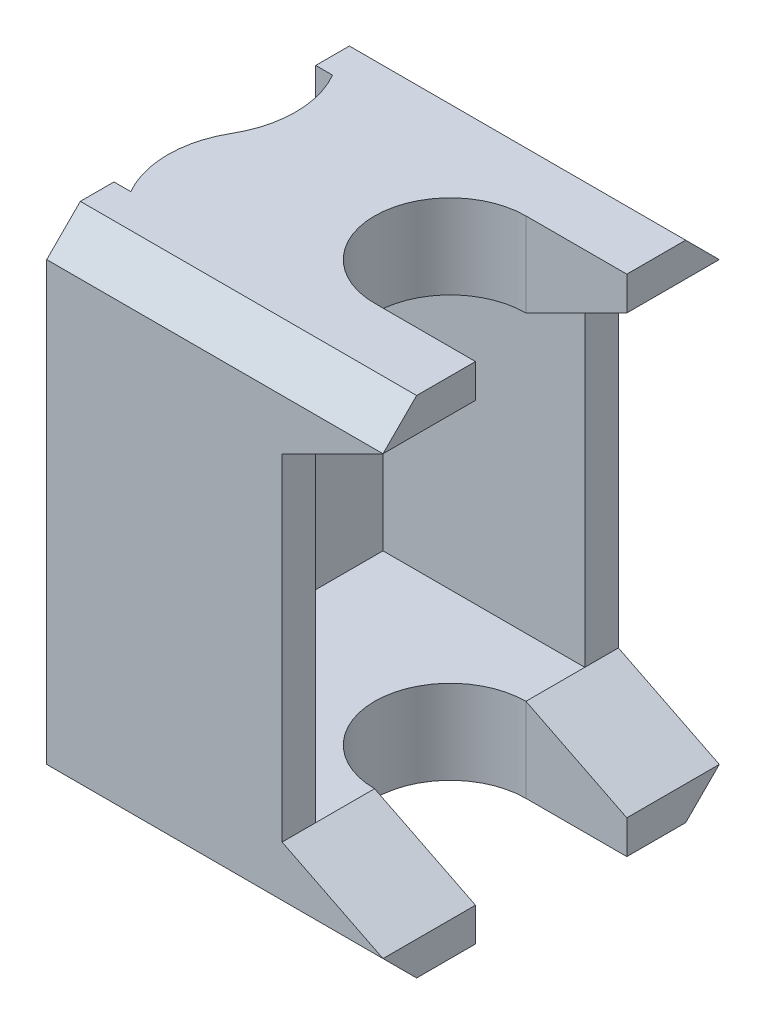
from build123d import *

# Parameters (mm, degrees)
BOSS_EXTRUDE1_DEPTH = 50
CUT_EXTRUDE1_DEPTH  = 151
SKETCH3_W           = 80
SKETCH3_H           = 100
CUT_EXTRUDE3_DEPTH  = 60
CUT_EXTRUDE4_DEPTH  = 101


with BuildPart() as part:
    # Sketch1 → Boss-Extrude1 (new body, symmetric)
    with BuildSketch(Plane.XY):
        Polygon((0, 0), (0, 10), (-30, 25), (-30, 125), (0, 140), (0, 150), (-100, 150), (-100, 0), align=None)
    extrude(amount=BOSS_EXTRUDE1_DEPTH, both=True)

    # Sketch2 → Cut-Extrude1 (cut, through all)
    with BuildSketch(Plane(origin=(0, 150, 0), x_dir=(1, 0, 0), z_dir=(0, 1, 0))):
        with BuildLine():
            Line((0, 22.5), (-30, 22.5))
            ThreePointArc((-30, 22.5), (-52.5, 0), (-30, -22.5))
            Line((-30, -22.5), (0, -22.5))
            Line((0, -22.5), (0, 22.5))
        make_face()
        with BuildLine():
            Line((-100, -30), (-95, -30))
            ThreePointArc((-95, -30), (-99.019237886, -15), (-95, 0))
            ThreePointArc((-95, 0), (-90.980762114, 15), (-95, 30))
            Line((-95, 30), (-100, 30))
            Line((-100, 30), (-100, -30))
        make_face()
    extrude(amount=-CUT_EXTRUDE1_DEPTH, mode=Mode.SUBTRACT)

    # Sketch3 → Cut-Extrude3 (cut)
    with BuildSketch(Plane(origin=(-30, 0, 0), x_dir=(0, 0, -1), z_dir=(1, 0, 0))):
        with Locations((0, 75)):
            Rectangle(SKETCH3_W, SKETCH3_H)
    extrude(amount=-CUT_EXTRUDE3_DEPTH, mode=Mode.SUBTRACT)

    # Sketch4 → Cut-Extrude4 (cut, through all)
    with BuildSketch(Plane(origin=(0, 0, 0), x_dir=(0, 0, -1), z_dir=(1, 0, 0))):
        Polygon((-50, 140), (-40, 150), (-50, 150), align=None)
        Polygon((50, 140), (50, 150), (40, 150), align=None)
        Polygon((-50, 10), (-50, 0), (-40, 0), align=None)
        Polygon((40, 0), (50, 0), (50, 10), align=None)
    extrude(amount=-CUT_EXTRUDE4_DEPTH, mode=Mode.SUBTRACT)


solid = part.part
